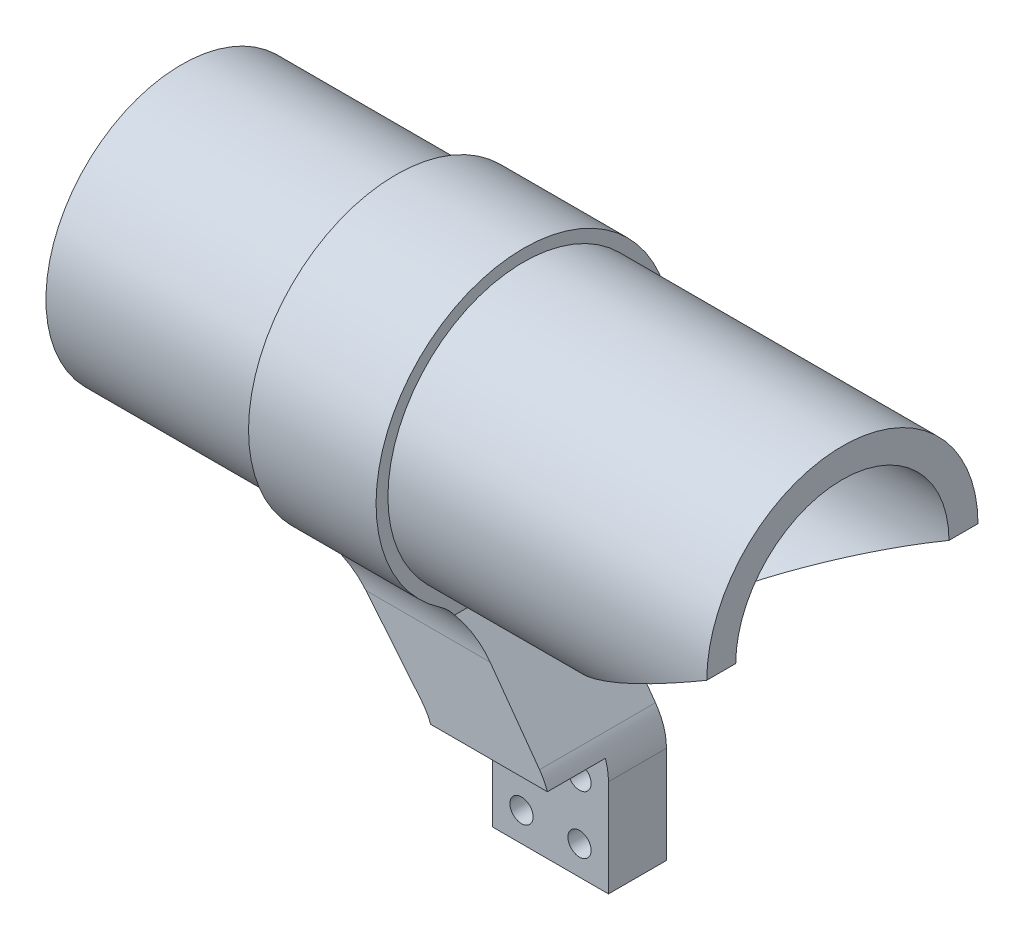
from build123d import *

# Parameters (mm, degrees)
CROQUIS1_R              = 23.4
CROQUIS1_R_2            = 18.4
SALIENTE_EXTRUIR1_DEPTH = 114
CROQUIS2_R              = 23.4
CROQUIS2_R_2            = 7.5
CROQUIS2_R_3            = 1.25
SALIENTE_EXTRUIR2_DEPTH = 5
CORTAR_EXTRUIR1_DEPTH   = 23.5
CROQUIS6_R              = 11.5
CORTAR_EXTRUIR2_DEPTH   = 2.5
CROQUIS9_R              = 2
SALIENTE_EXTRUIR3_DEPTH = 10
REDONDEO3_R             = 10
CROQUIS10_W             = 23.154362093
CROQUIS10_H             = 20
CORTAR_EXTRUIR3_DEPTH   = 10
SALIENTE_EXTRUIR4_DEPTH = 22
REDONDEO1_R             = 10
CROQUIS12_R             = 18.4
CORTAR_EXTRUIR4_DEPTH   = 78


with BuildPart() as part:
    # Croquis1 → Saliente-Extruir1 (new body)
    with BuildSketch(Plane(origin=(0, 0, 0), x_dir=(0, 0, -1), z_dir=(1, 0, 0))):
        Circle(CROQUIS1_R)
        Circle(CROQUIS1_R_2, mode=Mode.SUBTRACT)
    extrude(amount=SALIENTE_EXTRUIR1_DEPTH)

    # Croquis2 → Saliente-Extruir2 (add)
    with BuildSketch(Plane.ZY):
        Circle(CROQUIS2_R)
        Circle(CROQUIS2_R_2, mode=Mode.SUBTRACT)
        with Locations((-11.138131171, -8.481865008)):
            Circle(CROQUIS2_R_3, mode=Mode.SUBTRACT)
        with Locations((8.481865008, -11.138131171)):
            Circle(CROQUIS2_R_3, mode=Mode.SUBTRACT)
        with Locations((11.138131171, 8.481865008)):
            Circle(CROQUIS2_R_3, mode=Mode.SUBTRACT)
        with Locations((-8.481865008, 11.138131171)):
            Circle(CROQUIS2_R_3, mode=Mode.SUBTRACT)
    extrude(amount=-SALIENTE_EXTRUIR2_DEPTH)

    # Croquis4 → Cortar-Extruir1 (cut, symmetric)
    with BuildSketch(Plane.XY):
        Polygon((114, 0.1), (74, -23.4), (114, -23.4), align=None)
    extrude(amount=CORTAR_EXTRUIR1_DEPTH, both=True, mode=Mode.SUBTRACT)

    # Croquis6 → Cortar-Extruir2 (cut)
    with BuildSketch(Plane(origin=(5, 0, 0), x_dir=(0, 0, -1), z_dir=(1, 0, 0))):
        Circle(CROQUIS6_R)
    extrude(amount=-CORTAR_EXTRUIR2_DEPTH, mode=Mode.SUBTRACT)



with BuildPart() as body_2:
    # Croquis9 → Saliente-Extruir3 (new body, symmetric)
    with BuildSketch(Plane.XY):
        Polygon((73.650159213, -43.69341218), (73.650159213, -63.69341218), (53.650159213, -63.69341218), (53.650159213, -43.69341218), (37, -23.4), (59, -23.4), align=None)
        with Locations((58.650159213, -48.69341218)):
            Circle(CROQUIS9_R, mode=Mode.SUBTRACT)
        with Locations((58.650159213, -58.69341218)):
            Circle(CROQUIS9_R, mode=Mode.SUBTRACT)
        with Locations((68.650159213, -58.69341218)):
            Circle(CROQUIS9_R, mode=Mode.SUBTRACT)
        with Locations((68.650159213, -48.69341218)):
            Circle(CROQUIS9_R, mode=Mode.SUBTRACT)
    extrude(amount=SALIENTE_EXTRUIR3_DEPTH, both=True)

    # Redondeo3
    redondeo3_edges = [body_2.edges().sort_by_distance(p)[0] for p in [
        (53.650159213, -43.69341218, 0),
        (73.650159213, -43.69341218, 0),
    ]]
    fillet(redondeo3_edges, radius=REDONDEO3_R)

    # Croquis10 → Cortar-Extruir3 (cut)
    with BuildSketch(Plane.XY.offset(10)):
        with Locations((62.072978167, -53.69341218)):
            Rectangle(CROQUIS10_W, CROQUIS10_H)
    extrude(amount=-CORTAR_EXTRUIR3_DEPTH, mode=Mode.SUBTRACT)


with BuildPart() as part_1:
    add(part.part)

    add(body_2.part)  # Saliente-Extruir4 merges body 2
    # Croquis11 → Saliente-Extruir4 (add)
    with BuildSketch(Plane(origin=(37, 0, 0), x_dir=(0, 0, -1), z_dir=(1, 0, 0))):
        with BuildLine():
            Line((-10, -23.4), (10, -23.4))
            ThreePointArc((10, -23.4), (0, 25.447200239), (-10, -23.4))
        make_face()
    extrude(amount=SALIENTE_EXTRUIR4_DEPTH)

    # Redondeo1
    redondeo1_edges = [part_1.edges().sort_by_distance(p)[0] for p in [
        (48, -23.4, -10),
        (48, -23.4, 10),
    ]]
    fillet(redondeo1_edges, radius=REDONDEO1_R)

    # Croquis12 → Cortar-Extruir4 (cut, through all)
    with BuildSketch(Plane.ZY.offset(-37)):
        Circle(CROQUIS12_R)
    extrude(amount=-CORTAR_EXTRUIR4_DEPTH, mode=Mode.SUBTRACT)


solid = part_1.part
